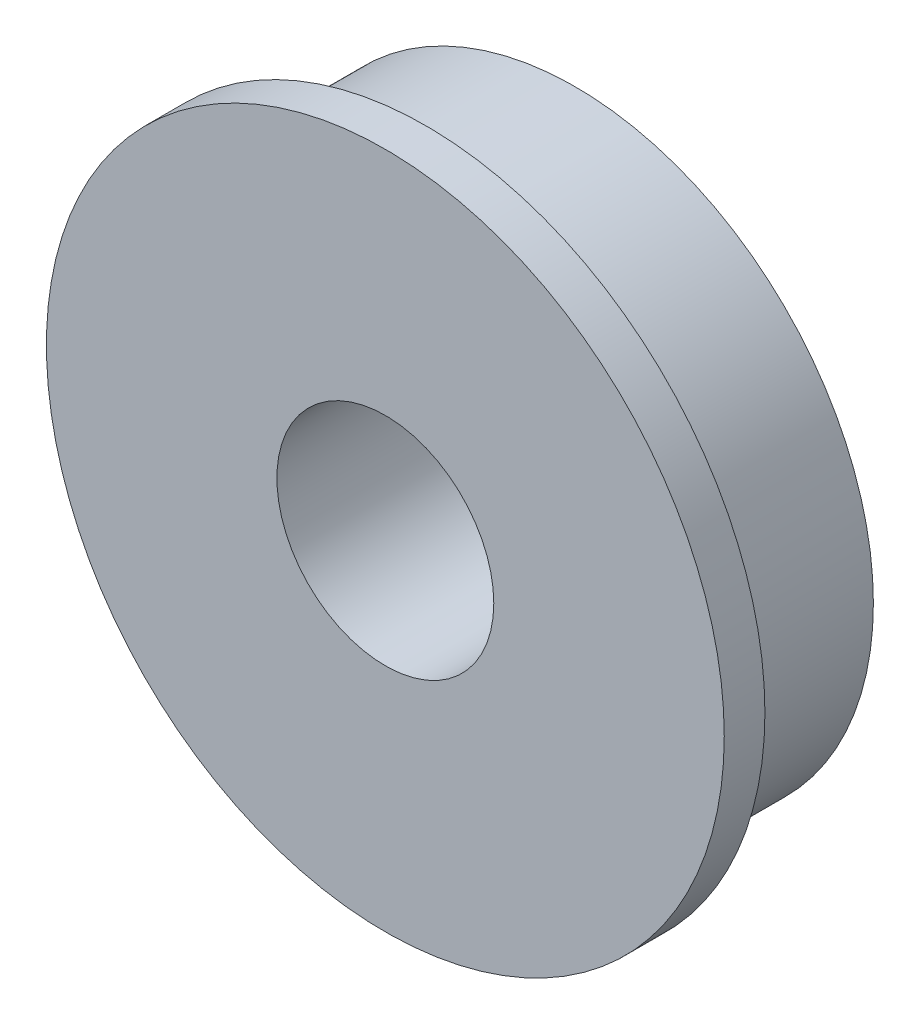
from build123d import *

# Parameters (mm, degrees)
ESQUISSE1_R        = 11
ESQUISSE1_R_2      = 4
BOSS_EXTRU_1_DEPTH = 5.5
ESQUISSE2_R        = 12.5
ESQUISSE2_R_2      = 4
BOSS_EXTRU_2_DEPTH = 1.5


with BuildPart() as part:
    # Esquisse1 → Boss.-Extru.1 (new body)
    with BuildSketch(Plane.XY):
        Circle(ESQUISSE1_R)
        Circle(ESQUISSE1_R_2, mode=Mode.SUBTRACT)
    extrude(amount=BOSS_EXTRU_1_DEPTH)

    # Esquisse2 → Boss.-Extru.2 (add)
    with BuildSketch(Plane.XY.offset(5.5)):
        Circle(ESQUISSE2_R)
        Circle(ESQUISSE2_R_2, mode=Mode.SUBTRACT)
    extrude(amount=BOSS_EXTRU_2_DEPTH)


solid = part.part
